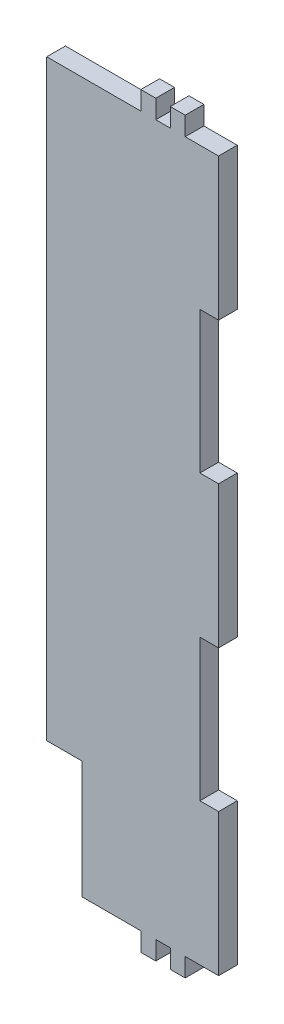
from build123d import *

# Parameters (mm, degrees)
BOSS_EXTRUDE1_DEPTH = 6.35
BOSS_EXTRUDE2_DEPTH = 6.35


with BuildPart() as part:
    # Sketch1 → Boss-Extrude1 (new body)
    with BuildSketch(Plane.XY):
        Polygon((12.5, 72.3975), (18.85, 72.3975), (18.85, 120.6625), (7.5, 120.6625), (7.5, 127.0125), (2.5, 127.0125), (2.5, 120.6625), (-2.5, 120.6625), (-2.5, 127.0125), (-7.5, 127.0125), (-7.5, 120.6625), (-39.5, 120.6625), (-39.5, -80.6625), (-27.5, -80.6625), (-27.5, -120.6625), (-7.5, -120.6625), (-7.5, -127.0125), (-2.5, -127.0125), (-2.5, -120.6625), (2.5, -120.6625), (2.5, -127.0125), (7.5, -127.0125), (7.5, -120.6625), (18.85, -120.6625), (18.85, -72.3975), (12.5, -72.3975), (12.5, -24.1325), (18.85, -24.1325), (18.85, 24.1325), (12.5, 24.1325), align=None)
    extrude(amount=BOSS_EXTRUDE1_DEPTH)

    # Sketch3 → Boss-Extrude2 (add)
    with BuildSketch(Plane.XY.offset(6.35)):
        Polygon((-27.54064, -80.70314), (-27.54064, -120.70314), (-7.54064, -120.70314), (-7.54064, -127.05314), (-2.45936, -127.05314), (-2.45936, -120.70314), (2.45936, -120.70314), (2.45936, -127.05314), (7.54064, -127.05314), (7.54064, -120.70314), (18.89064, -120.70314), (18.89064, -72.35686), (12.54064, -72.35686), (12.54064, -24.17314), (18.89064, -24.17314), (18.89064, 24.17314), (12.54064, 24.17314), (12.54064, 72.35686), (18.89064, 72.35686), (18.89064, 120.70314), (7.54064, 120.70314), (7.54064, 127.05314), (2.45936, 127.05314), (2.45936, 120.70314), (-2.45936, 120.70314), (-2.45936, 127.05314), (-7.54064, 127.05314), (-7.54064, 120.70314), (-39.54064, 120.70314), (-39.54064, -80.70314), align=None)
    extrude(amount=-BOSS_EXTRUDE2_DEPTH)


solid = part.part
